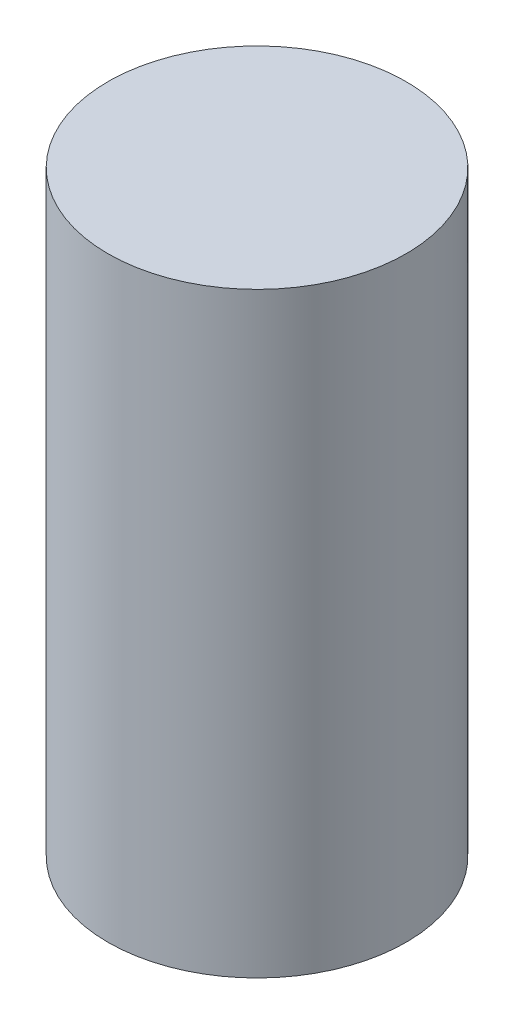
from build123d import *

# Parameters (mm, degrees)
SKETCH1_R           = 0.25
BOSS_EXTRUDE1_DEPTH = 1


with BuildPart() as part:
    # Sketch1 → Boss-Extrude1 (new body)
    with BuildSketch(Plane(origin=(0, 0, 0), x_dir=(1, 0, 0), z_dir=(0, 1, 0))):
        Circle(SKETCH1_R)
    extrude(amount=BOSS_EXTRUDE1_DEPTH)


solid = part.part
